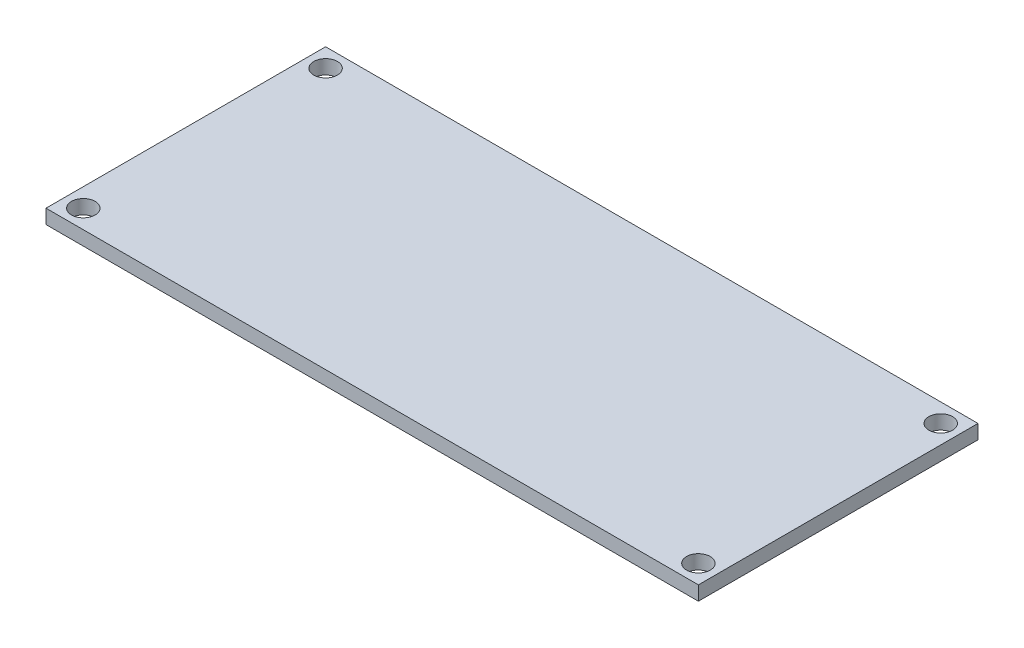
from build123d import *

# Parameters (mm, degrees)
SKETCH1_W               = 70
SKETCH1_H               = 30
BOSS_EXTRUDE1_DEPTH     = 1.524
SKETCH2_R               = 1.27
CUT_EXTRUDE1_DEPTH      = 2.524
MIRROR2_COPY_1_SKETCH_R = 1.27
MIRROR2_COPY_1_DEPTH    = 2.524


with BuildPart() as part:
    # Sketch1 → Boss-Extrude1 (new body)
    with BuildSketch(Plane(origin=(0, 0, 0), x_dir=(1, 0, 0), z_dir=(0, 1, 0))):
        with Locations((5.547619048, 1.30952381)):
            Rectangle(SKETCH1_W, SKETCH1_H)
    extrude(amount=BOSS_EXTRUDE1_DEPTH)

    # Sketch2 → Cut-Extrude1 (cut, through all)
    with BuildSketch(Plane(origin=(0, 1.524, 0), x_dir=(1, 0, 0), z_dir=(0, 1, 0))):
        with Locations((-27.452380952, -11.69047619)):
            Circle(SKETCH2_R)
    cut_extrude1 = extrude(amount=-CUT_EXTRUDE1_DEPTH, mode=Mode.SUBTRACT)

    # Mirror1: Cut-Extrude1 across plane
    add(cut_extrude1.mirror(Plane.ZY.offset(-5.547619048)), mode=Mode.SUBTRACT)

    # Mirror2: Cut-Extrude1 across plane
    add(cut_extrude1.mirror(Plane(origin=(0, 0, -1.30952381), x_dir=(1, 0, 0), z_dir=(0, 0, -1))), mode=Mode.SUBTRACT)

    # Mirror2 copy 1 sketch → Mirror2 copy 1 (cut, through all)
    with BuildSketch(Plane(origin=(11.095238095, 1.524, -2.619047619), x_dir=(-1, 0, 0), z_dir=(0, 1, 0))):
        with Locations((-27.452380952, -11.69047619)):
            Circle(MIRROR2_COPY_1_SKETCH_R)
    extrude(amount=-MIRROR2_COPY_1_DEPTH, mode=Mode.SUBTRACT)


solid = part.part
